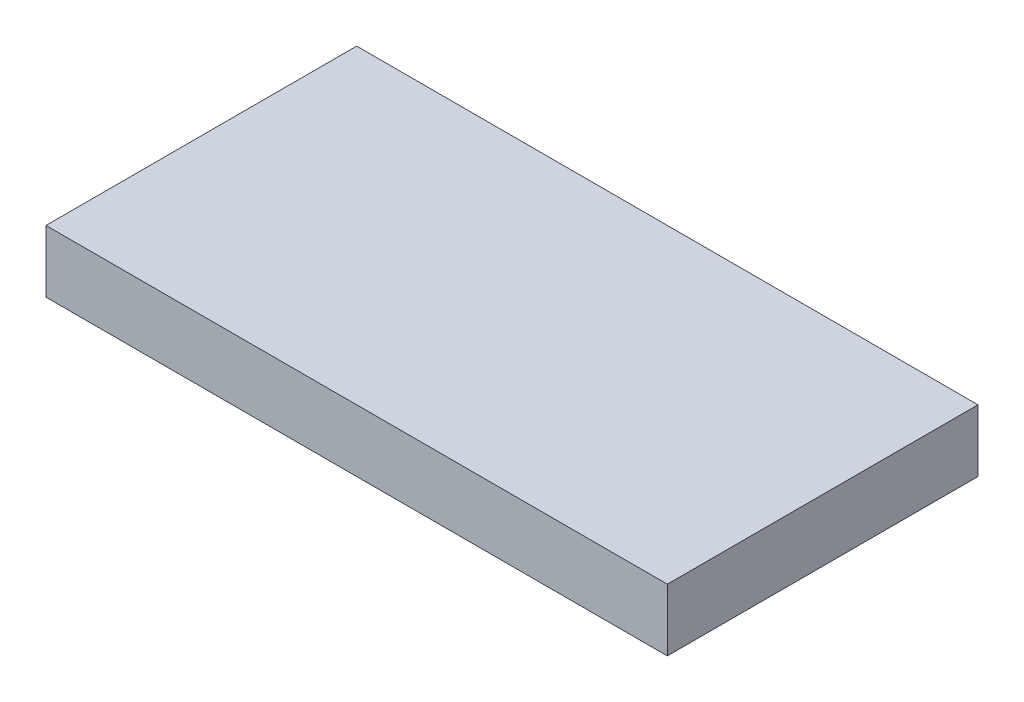
from build123d import *

# Parameters (mm, degrees)
SKETCH1_W           = 100
SKETCH1_H           = 50
BOSS_EXTRUDE1_DEPTH = 10


with BuildPart() as part:
    # Sketch1 → Boss-Extrude1 (new body)
    with BuildSketch(Plane(origin=(0, 0, 0), x_dir=(1, 0, 0), z_dir=(0, 1, 0))):
        with Locations((43.113772455, 23.877245509)):
            Rectangle(SKETCH1_W, SKETCH1_H)
    extrude(amount=BOSS_EXTRUDE1_DEPTH)


solid = part.part
